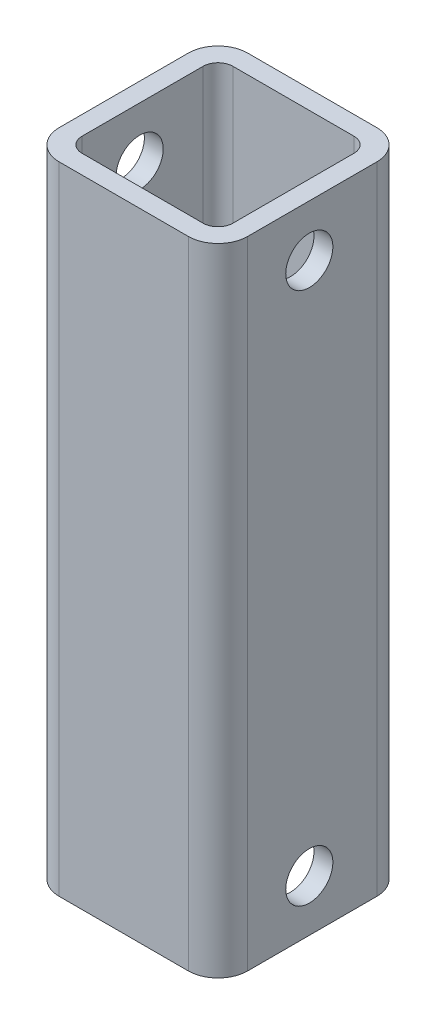
from build123d import *

# Parameters (mm, degrees)
BOSS_EXTRUDE1_DEPTH     = 85.725
SKETCH2_R               = 3.175
CUT_EXTRUDE1_DEPTH      = 1
CUT_EXTRUDE1_DEPTH_BACK = 26.4


with BuildPart() as part:
    # Sketch1 → Boss-Extrude1 (new body)
    with BuildSketch(Plane(origin=(0, 0, 0), x_dir=(1, 0, 0), z_dir=(0, 1, 0))):
        with BuildLine():
            Line((4, 0), (21.4, 0))
            ThreePointArc((21.4, 0), (24.228427125, 1.171572875), (25.4, 4))
            Line((25.4, 4), (25.4, 21.4))
            ThreePointArc((25.4, 21.4), (24.228427125, 24.228427125), (21.4, 25.4))
            Line((21.4, 25.4), (4, 25.4))
            ThreePointArc((4, 25.4), (1.171572875, 24.228427125), (0, 21.4))
            Line((0, 21.4), (0, 4))
            ThreePointArc((0, 4), (1.171572875, 1.171572875), (4, 0))
        make_face()
        with BuildLine():
            Line((20.86, 2.54), (4.54, 2.54))
            ThreePointArc((4.54, 2.54), (3.125786438, 3.125786438), (2.54, 4.54))
            Line((2.54, 4.54), (2.54, 20.86))
            ThreePointArc((2.54, 20.86), (3.125786438, 22.274213562), (4.54, 22.86))
            Line((4.54, 22.86), (20.86, 22.86))
            ThreePointArc((20.86, 22.86), (22.274213562, 22.274213562), (22.86, 20.86))
            Line((22.86, 20.86), (22.86, 4.54))
            ThreePointArc((22.86, 4.54), (22.274213562, 3.125786438), (20.86, 2.54))
        make_face(mode=Mode.SUBTRACT)
    extrude(amount=BOSS_EXTRUDE1_DEPTH)

    # Sketch2 → Cut-Extrude1 (cut, two sides)
    with BuildSketch(Plane(origin=(25.4, 0, 0), x_dir=(0, 0, -1), z_dir=(1, 0, 0))) as cut_extrude1_sk:
        with Locations((12.303125, 6.9453125)):
            Circle(SKETCH2_R)
        with Locations((12.303125, 78.7796875)):
            Circle(SKETCH2_R)
    extrude(amount=CUT_EXTRUDE1_DEPTH, mode=Mode.SUBTRACT)
    extrude(cut_extrude1_sk.sketch, amount=-CUT_EXTRUDE1_DEPTH_BACK, mode=Mode.SUBTRACT)


solid = part.part
